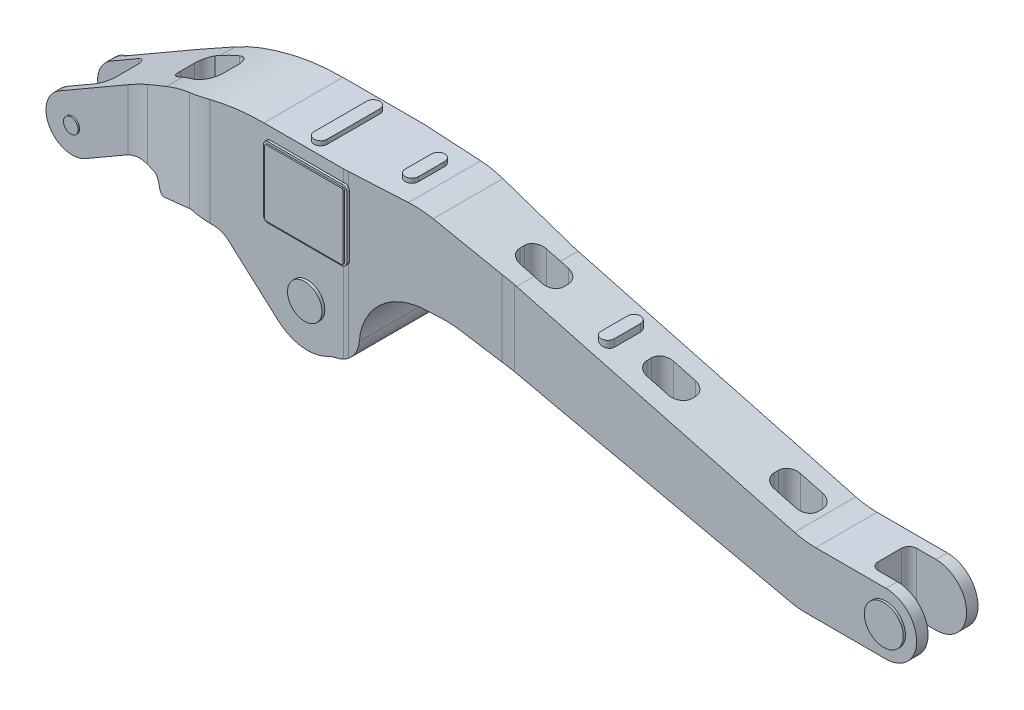
from build123d import *

# Parameters (mm, degrees)
EXTRUDE1_DEPTH          = 188.214
CUT_EXTRUDE2_DEPTH      = 387.604
CUT_EXTRUDE2_DEPTH_BACK = 188.214
EXTRUDE2_DEPTH          = 9.999999
EXTRUDE3_DEPTH          = 5.334
EXTRUDE3_DEPTH_BACK     = 6.35
EXTRUDE4_DEPTH          = 3.175
SKETCH9_R               = 39.37952
EXTRUDE5_DEPTH          = 6.35
EXTRUDE6_REACH          = 315.148
SKETCH11_R              = 16.89387
EXTRUDE7_DEPTH          = 3.175
EXTRUDE7_DEPTH_BACK     = 128.905
SKETCH12_R              = 59.97489
EXTRUDE8_DEPTH          = 5.000004
SKETCH13_R              = 54.974888
EXTRUDE9_DEPTH          = 8.00024
CUT_EXTRUDE3_DEPTH      = 537.21
CUT_EXTRUDE3_DEPTH_BACK = 196.215
SKETCH15_R              = 63.5
EXTRUDE10_DEPTH         = 5
SKETCH16_R              = 53.975
EXTRUDE11_DEPTH         = 10
SKETCH17_R              = 77.089
EXTRUDE12_DEPTH         = 15
SKETCH18_R              = 92.837
EXTRUDE13_DEPTH         = 62.5
SKETCH19_R              = 44.45
EXTRUDE14_DEPTH         = 5
SKETCH20_R              = 44.45
EXTRUDE15_DEPTH         = 5


with BuildPart() as part:
    # Sketch3 → Extrude1 (new body)
    with BuildSketch(Plane.XY):
        with BuildLine():
            Line((-511.142362, 139.733152), (-619, 77.46152))
            ThreePointArc((-619, 77.46152), (-640.961526, -4.500006), (-559, -26.46153))
            Line((-559, -26.46153), (-467.09034, 26.60253))
            ThreePointArc((-467.09034, 26.60253), (-442.972244, 36.592572), (-417.09034, 39.99999))
            Line((-417.09034, 39.99999), (-391.17663, 39.99999))
            ThreePointArc((-391.17663, 39.99999), (-381.195356, 36.719182), (-375.10704, 28.15636))
            Line((-375.10704, 28.15636), (-370.38946, 15.1949))
            ThreePointArc((-370.38946, 15.1949), (-365.218715, 9.552021), (-357.572329, 9.218177))
            Line((-357.572329, 9.218177), (-271.67443, 39.99999))
            Line((-271.67443, 39.99999), (-214.06736, 39.999994))
            ThreePointArc((-214.06736, 39.999994), (-196.251471, 36.718237), (-180.77428, 27.30376))
            Line((-180.77428, 27.30376), (-66.586153, -74.607521))
            ThreePointArc((-66.586153, -74.607521), (-13.162151, -99.129994), (44.81, -89.398332))
            ThreePointArc((44.81, -89.398332), (56.196504, -84.53489), (68.090044, -81.092621))
            ThreePointArc((68.090044, -81.092621), (101.504206, -61.043895), (116.356325, -25.017901))
            ThreePointArc((116.356325, -25.017901), (160.599521, 67.463386), (256.000005, 104.99999))
            Line((256.000005, 104.99999), (292.350036, 104.99999))
            ThreePointArc((292.350036, 104.99999), (312.876554, 103.87605), (333.15764, 100.51767))
            Line((333.15764, 100.51767), (1083.05901, -66.23295))
            ThreePointArc((1083.05901, -66.23295), (1100.103756, -69.05542), (1117.35477, -70.00001))
            Line((1117.35477, -70.00001), (1300, -70.00001))
            ThreePointArc((1300, -70.00001), (1370.000001, -9e-06), (1300, 69.999991))
            Line((1300, 69.999991), (1139.56741, 69.999991))
            ThreePointArc((1139.56741, 69.999991), (1115.20712, 71.584927), (1091.25757, 76.31301))
            Line((1091.25757, 76.31301), (457.14407, 244.92122))
            Line((457.14407, 244.92122), (276.268225, 293.01538))
            ThreePointArc((276.268225, 293.01538), (249.77086, 298.24645), (222.819059, 299.999998))
            Line((222.819059, 299.999998), (-99.577442, 299.999994))
            ThreePointArc((-99.577442, 299.999994), (-228.986969, 282.962905), (-349.57745, 233.01269))
            Line((-349.57745, 233.01269), (-504.17545, 143.7555))
            Line((-504.17545, 143.7555), (-511.142362, 139.733152))
        make_face()
    extrude(amount=-EXTRUDE1_DEPTH)

    # Sketch4 → Cut-Extrude2 (cut, two sides)
    with BuildSketch(Plane(origin=(0, 0, 0), x_dir=(1, 0, 0), z_dir=(0, 1, 0))) as cut_extrude2_sk:
        with BuildLine():
            Line((-462.18546, 52.14466), (-660.54717, 52.14466))
            Line((-660.54717, 52.14466), (-660.54717, 70))
            Line((-660.54717, 70), (-555.87822, 70))
            ThreePointArc((-555.87822, 70), (-536.252719, 79.119389), (-530.56733, 100))
            Line((-530.56733, 100), (-530.56733, 140))
            ThreePointArc((-530.56733, 140), (-537.573661, 159.465227), (-555.37822, 170))
            Line((-555.37822, 170), (-672.385696, 170))
            Line((-672.385696, 170), (-703.508736, -54.172588))
            Line((-703.508736, -54.172588), (1473.708419, -54.172588))
            Line((1473.708419, -54.172588), (1473.708419, 231.5))
            Line((1473.708419, 231.5), (-663.136847, 231.5))
            Line((-663.136847, 231.5), (-663.136847, 187.999996))
            Line((-663.136847, 187.999996), (-439.322301, 187.999996))
            ThreePointArc((-439.322301, 187.999996), (-435.001004, 187.953307), (-430.681724, 187.81326))
            Line((-430.681724, 187.81326), (-254.14553, 180.17926))
            ThreePointArc((-254.14553, 180.17926), (-249.999023, 180.04482), (-245.85058, 180))
            Line((-245.85058, 180), (82.26233, 180))
            ThreePointArc((82.26233, 180), (95.022455, 179.688141), (107.75211, 178.75331))
            Line((107.75211, 178.75331), (434.261489, 160.862363))
            Line((434.261489, 160.862363), (447.48512, 160.137798))
            ThreePointArc((447.48512, 160.137798), (450.000947, 160.034456), (452.51866, 160))
            Line((452.51866, 160), (798.551196, 160))
            Line((798.551196, 160), (1086.63216, 160))
            Line((1086.63216, 160), (1385.298155, 160))
            Line((1385.298155, 160), (1385.298155, 133.999998))
            Line((1385.298155, 133.999998), (1256, 133.999998))
            ThreePointArc((1256, 133.999998), (1243.75288, 128.930418), (1238.671888, 116.688028))
            Line((1238.671888, 116.688028), (1238.622222, 63.393973))
            ThreePointArc((1238.622222, 63.393973), (1243.706324, 51.095559), (1255.999995, 45.999998))
            Line((1255.999995, 45.999998), (1385.298155, 45.999998))
            Line((1385.298155, 45.999998), (1385.298155, 20))
            Line((1385.298155, 20), (1352, 20))
            Line((1352, 20), (1086.63216, 20))
            Line((1086.63216, 20), (452.51866, 20))
            ThreePointArc((452.51866, 20), (438.709181, 19.656265), (424.933904, 18.625911))
            Line((424.933904, 18.625911), (93.248409, 0.451953))
            ThreePointArc((93.248409, 0.451953), (87.760016, 0.113036), (82.26233, 0))
            Line((82.26233, 0), (-222.42616, 0))
            ThreePointArc((-222.42616, 0), (-249.741612, 1.874109), (-276.54514, 7.46133))
            Line((-276.54514, 7.46133), (-409.51666, 44.83711))
            ThreePointArc((-409.51666, 44.83711), (-435.598796, 50.309064), (-462.18546, 52.14466))
        make_face()
    extrude(amount=CUT_EXTRUDE2_DEPTH, mode=Mode.SUBTRACT)
    extrude(cut_extrude2_sk.sketch, amount=-CUT_EXTRUDE2_DEPTH_BACK, mode=Mode.SUBTRACT)

    # Sketch6 → Extrude2 (add)
    with BuildSketch(Plane(origin=(-4e-06, 299.999995, 0), x_dir=(-1, 0, 0), z_dir=(0, 1, 0))):
        with BuildLine():
            Line((-193, -120), (-193, -60))
            ThreePointArc((-193, -60), (-178, -45), (-163, -60))
            Line((-163, -60), (-163, -120))
            ThreePointArc((-163, -120), (-178, -135), (-193, -120))
        make_face()
        with BuildLine():
            Line((-15, -150), (-15, -30))
            ThreePointArc((-15, -30), (0, -15), (15, -30))
            Line((15, -30), (15, -150))
            ThreePointArc((15, -150), (0, -165), (-15, -150))
        make_face()
    extrude(amount=EXTRUDE2_DEPTH)

    # Sketch7 → Extrude3 (add, two sides)
    with BuildSketch(Plane.XY) as extrude3_sk:
        with BuildLine():
            Line((-84.99999, 272.999995), (82.26234, 272.999995))
            ThreePointArc((82.26234, 272.999995), (91.062577, 271.097035), (95.00001, 262.999995))
            Line((95.00001, 262.999995), (95.00001, 121.999995))
            ThreePointArc((95.00001, 121.999995), (90.35938, 114.798665), (82.26234, 111.999995))
            Line((82.26234, 111.999995), (-84.99999, 111.999995))
            ThreePointArc((-84.99999, 111.999995), (-92.071058, 114.928928), (-94.99999, 121.999995))
            Line((-94.99999, 121.999995), (-94.99999, 262.999995))
            ThreePointArc((-94.99999, 262.999995), (-92.071058, 270.071063), (-84.99999, 272.999995))
        make_face()
    extrude(amount=EXTRUDE3_DEPTH)
    extrude(extrude3_sk.sketch, amount=-EXTRUDE3_DEPTH_BACK)

    # Sketch8 → Extrude4 (add)
    with BuildSketch(Plane.XY.offset(5.334)):
        Polygon((87, 116.99999), (90, 119.99999), (90, 264.99999), (87, 267.99999), (-87, 267.99999), (-90, 264.99999), (-90, 119.99999), (-87, 116.99999), align=None)
    extrude(amount=EXTRUDE4_DEPTH)

    # Sketch9 → Extrude5 (add)
    with BuildSketch(Plane.XY):
        Circle(SKETCH9_R)
    extrude(amount=EXTRUDE5_DEPTH)

    # Extrude6: up to this face of the body (flat: up to its plane)
    extrude6_end = Plane(part.part.faces().sort_by_distance((774.20082, 160.617115, -90))[0])
    # Sketch10 → Extrude6 (add, up to the picked face)
    with BuildSketch(Plane(origin=(0, 213.148205, 0), x_dir=(-1, 0, 0), z_dir=(0, 1, 0)), mode=Mode.PRIVATE) as extrude6_sk1:
        with BuildLine():
            Line((-610, -120), (-610, -60))
            ThreePointArc((-610, -60), (-625, -45), (-640, -60))
            Line((-640, -60), (-640, -120))
            ThreePointArc((-640, -120), (-625, -135), (-610, -120))
        make_face()
    extrude6_tool1 = split(extrude(extrude6_sk1.sketch, amount=-EXTRUDE6_REACH, mode=Mode.PRIVATE), bisect_by=extrude6_end, keep=Keep.BOTH, mode=Mode.PRIVATE)
    add(extrude6_tool1.solids().sort_by_distance((625, 213.148205, -90))[0])

    # Sketch11 → Extrude7 (add, two sides)
    with BuildSketch(Plane.XY.offset(-52.14466)) as extrude7_sk:
        with Locations((-589.048253, 25.50115)):
            Circle(SKETCH11_R)
    extrude(amount=EXTRUDE7_DEPTH)
    extrude(extrude7_sk.sketch, amount=-EXTRUDE7_DEPTH_BACK)

    # Sketch12 → Extrude8 (add)
    with BuildSketch(Plane(origin=(0, 0, -187.999996), x_dir=(-1, 0, 0), z_dir=(0, 0, -1))):
        with Locations((589.048253, 25.50115)):
            Circle(SKETCH12_R)
    extrude(amount=EXTRUDE8_DEPTH)

    # Sketch13 → Extrude9 (add)
    with BuildSketch(Plane(origin=(0, 0, -193), x_dir=(-1, 0, 0), z_dir=(0, 0, -1))):
        with Locations((589.048253, 25.50115)):
            Circle(SKETCH13_R)
    extrude(amount=EXTRUDE9_DEPTH)

    # Sketch14 → Cut-Extrude3 (cut, two sides)
    with BuildSketch(Plane(origin=(0, 0, 0), x_dir=(1, 0, 0), z_dir=(0, 1, 0))) as cut_extrude3_sk:
        with BuildLine():
            Line((-362.0433, 150.92104), (-303.908391, 148.124039))
            ThreePointArc((-303.908391, 148.124039), (-283.704579, 138.53335), (-276.30231, 117.42928))
            Line((-276.30231, 117.42928), (-276.347492, 82.98124))
            ThreePointArc((-276.347492, 82.98124), (-286.727793, 60.531297), (-310.53788, 53.83575))
            Line((-310.53788, 53.83575), (-366.64824, 69.3704))
            ThreePointArc((-366.64824, 69.3704), (-379.368497, 78.483893), (-383.17814, 93.66109))
            Line((-383.17814, 93.66109), (-383.17814, 124.86702))
            ThreePointArc((-383.17814, 124.86702), (-377.230061, 141.641207), (-362.0433, 150.92104))
        make_face()
        with BuildLine():
            Line((425, 120), (475, 120))
            ThreePointArc((475, 120), (492.67767, 112.67767), (500, 95))
            Line((500, 95), (500, 85))
            ThreePointArc((500, 85), (492.67767, 67.32233), (475, 60))
            Line((475, 60), (425, 60))
            ThreePointArc((425, 60), (407.32233, 67.32233), (400, 85))
            Line((400, 85), (400, 95))
            ThreePointArc((400, 95), (407.32233, 112.67767), (425, 120))
        make_face()
        with BuildLine():
            Line((715, 120), (765, 120))
            ThreePointArc((765, 120), (782.67767, 112.67767), (790, 95))
            Line((790, 95), (790, 87.404831))
            ThreePointArc((790, 87.404831), (782.811044, 68.857427), (765, 60))
            Line((765, 60), (715, 60))
            ThreePointArc((715, 60), (697.32233, 67.32233), (690, 85))
            Line((690, 85), (690, 95))
            ThreePointArc((690, 95), (697.32233, 112.67767), (715, 120))
        make_face()
        with BuildLine():
            Line((1005, 120), (1055, 120))
            ThreePointArc((1055, 120), (1072.67767, 112.67767), (1080, 95))
            Line((1080, 95), (1080, 85))
            ThreePointArc((1080, 85), (1072.67767, 67.32233), (1055, 60))
            Line((1055, 60), (1005, 60))
            ThreePointArc((1005, 60), (987.32233, 67.32233), (980, 85))
            Line((980, 85), (980, 95))
            ThreePointArc((980, 95), (987.32233, 112.67767), (1005, 120))
        make_face()
    extrude(amount=CUT_EXTRUDE3_DEPTH, mode=Mode.SUBTRACT)
    extrude(cut_extrude3_sk.sketch, amount=-CUT_EXTRUDE3_DEPTH_BACK, mode=Mode.SUBTRACT)

    # Sketch15 → Extrude10 (add)
    with BuildSketch(Plane(origin=(0, 0, -180), x_dir=(-1, 0, 0), z_dir=(0, 0, -1))):
        Circle(SKETCH15_R)
    extrude(amount=EXTRUDE10_DEPTH)

    # Sketch16 → Extrude11 (add)
    with BuildSketch(Plane(origin=(0, 0, -185), x_dir=(-1, 0, 0), z_dir=(0, 0, -1))):
        Circle(SKETCH16_R)
    extrude(amount=EXTRUDE11_DEPTH)

    # Sketch17 → Extrude12 (add)
    with BuildSketch(Plane(origin=(0, 0, -195), x_dir=(-1, 0, 0), z_dir=(0, 0, -1))):
        Circle(SKETCH17_R)
    extrude(amount=EXTRUDE12_DEPTH)

    # Sketch18 → Extrude13 (add)
    with BuildSketch(Plane(origin=(0, 0, -210), x_dir=(-1, 0, 0), z_dir=(0, 0, -1))):
        Circle(SKETCH18_R)
    extrude(amount=EXTRUDE13_DEPTH)

    # Sketch19 → Extrude14 (add)
    with BuildSketch(Plane.XY.offset(-20)):
        with Locations((1300, 0)):
            Circle(SKETCH19_R)
    extrude(amount=EXTRUDE14_DEPTH)

    # Sketch20 → Extrude15 (add)
    with BuildSketch(Plane(origin=(0, 0, -160), x_dir=(-1, 0, 0), z_dir=(0, 0, -1))):
        with Locations((-1300, 0)):
            Circle(SKETCH20_R)
    extrude(amount=EXTRUDE15_DEPTH)


solid = part.part
